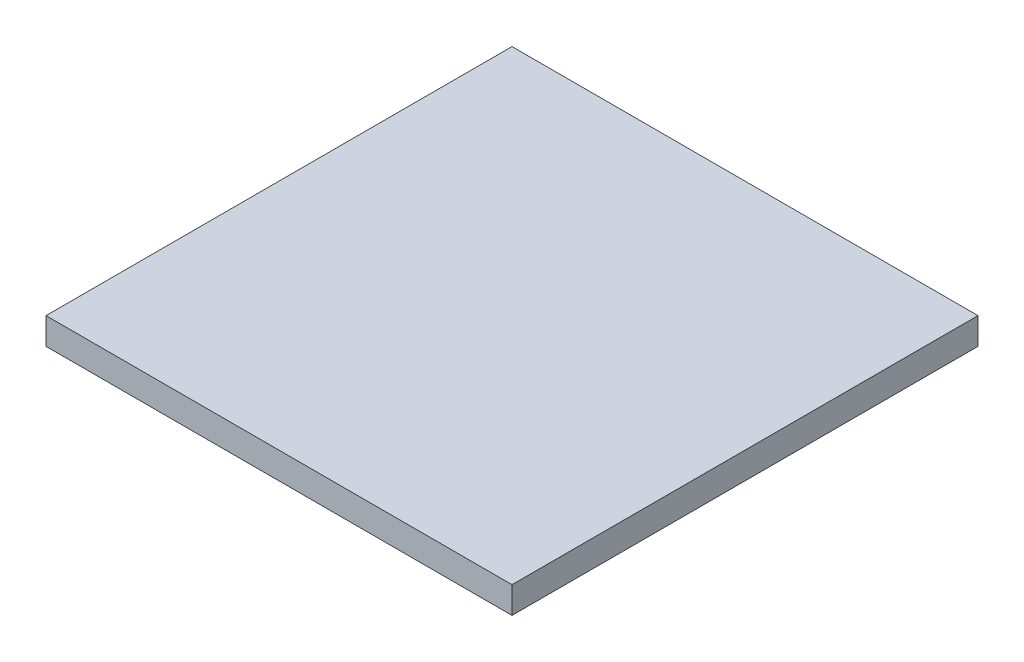
from build123d import *

# Parameters (mm, degrees)
SKETCH1_W           = 350
SKETCH1_H           = 350
BOSS_EXTRUDE1_DEPTH = 20


with BuildPart() as part:
    # Sketch1 → Boss-Extrude1 (new body)
    with BuildSketch(Plane(origin=(0, 0, 0), x_dir=(1, 0, 0), z_dir=(0, 1, 0))):
        with Locations((-17.921686747, -64.834337349)):
            Rectangle(SKETCH1_W, SKETCH1_H)
    extrude(amount=BOSS_EXTRUDE1_DEPTH)


solid = part.part
